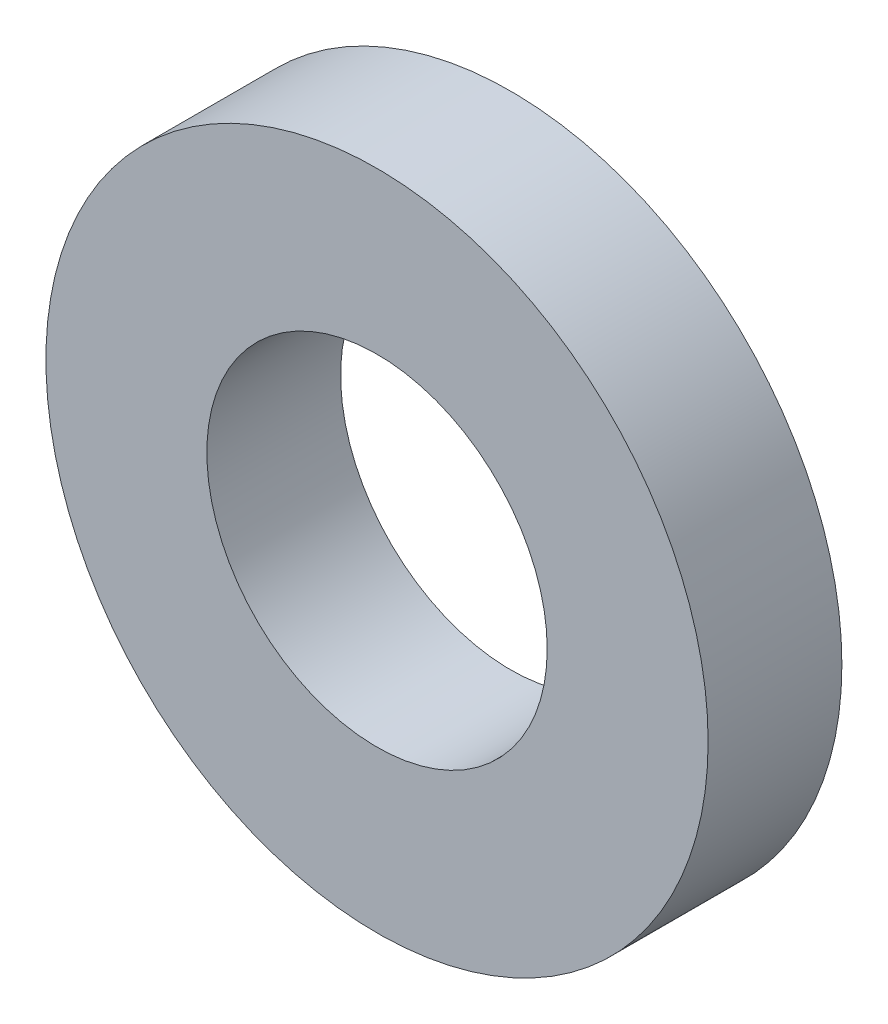
from build123d import *

# Parameters (mm, degrees)
SKETCH1_R      = 6.35
SKETCH1_R_2    = 3.2639
EXTRUDE1_DEPTH = 2.5654


with BuildPart() as part:
    # Sketch1 → Extrude1 (new body)
    with BuildSketch(Plane.XY):
        Circle(SKETCH1_R)
        Circle(SKETCH1_R_2, mode=Mode.SUBTRACT)
    extrude(amount=-EXTRUDE1_DEPTH)


solid = part.part
